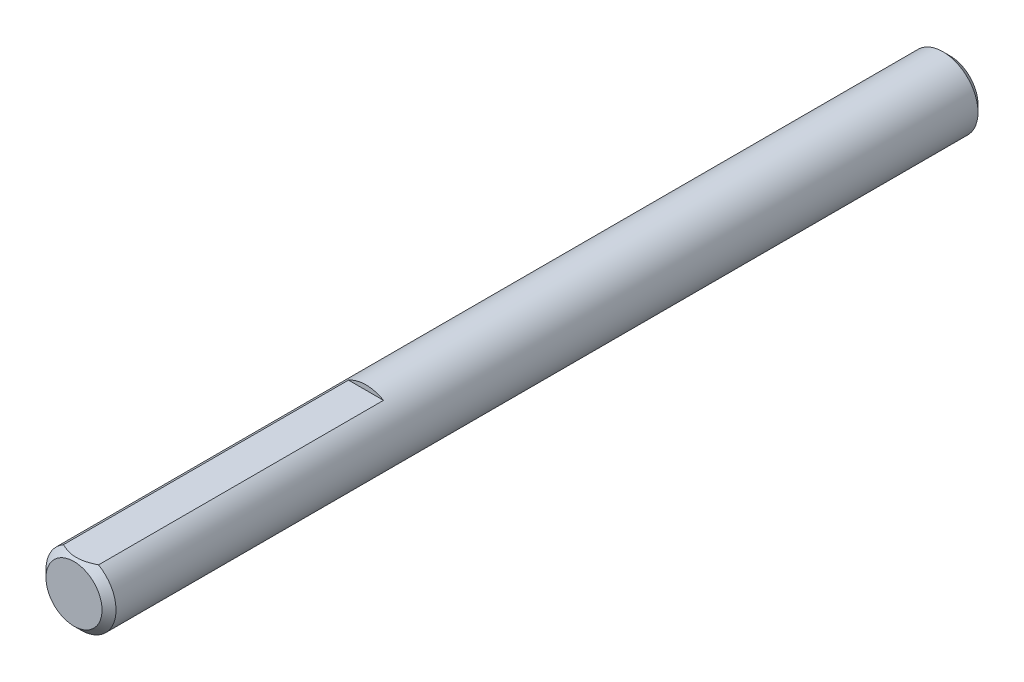
from build123d import *

# Parameters (mm, degrees)
SKETCH1_R      = 3.048
EXTRUDE1_DEPTH = 38.1
CHAMFER1_SIZE  = 0.6096
EXTRUDE7_DEPTH = 26.4


with BuildPart() as part:
    # Sketch1 → Extrude1 (new body, symmetric)
    with BuildSketch(Plane.XY):
        Circle(SKETCH1_R)
    extrude(amount=EXTRUDE1_DEPTH, both=True)

    # Chamfer1
    chamfer1_edges = [part.edges().sort_by_distance(p)[0] for p in [
        (-3.048, 0, -38.1),
        (-3.048, 0, 38.1),
    ]]
    chamfer(chamfer1_edges, length=CHAMFER1_SIZE)

    # Sketch13 → Extrude7 (cut, through all)
    with BuildSketch(Plane.XY.offset(12.7)):
        with BuildLine():
            Line((-1.524, 2.639645431), (1.524, 2.639645431))
            ThreePointArc((1.524, 2.639645431), (0, 3.048), (-1.524, 2.639645431))
        make_face()
    extrude(amount=EXTRUDE7_DEPTH, mode=Mode.SUBTRACT)


solid = part.part
